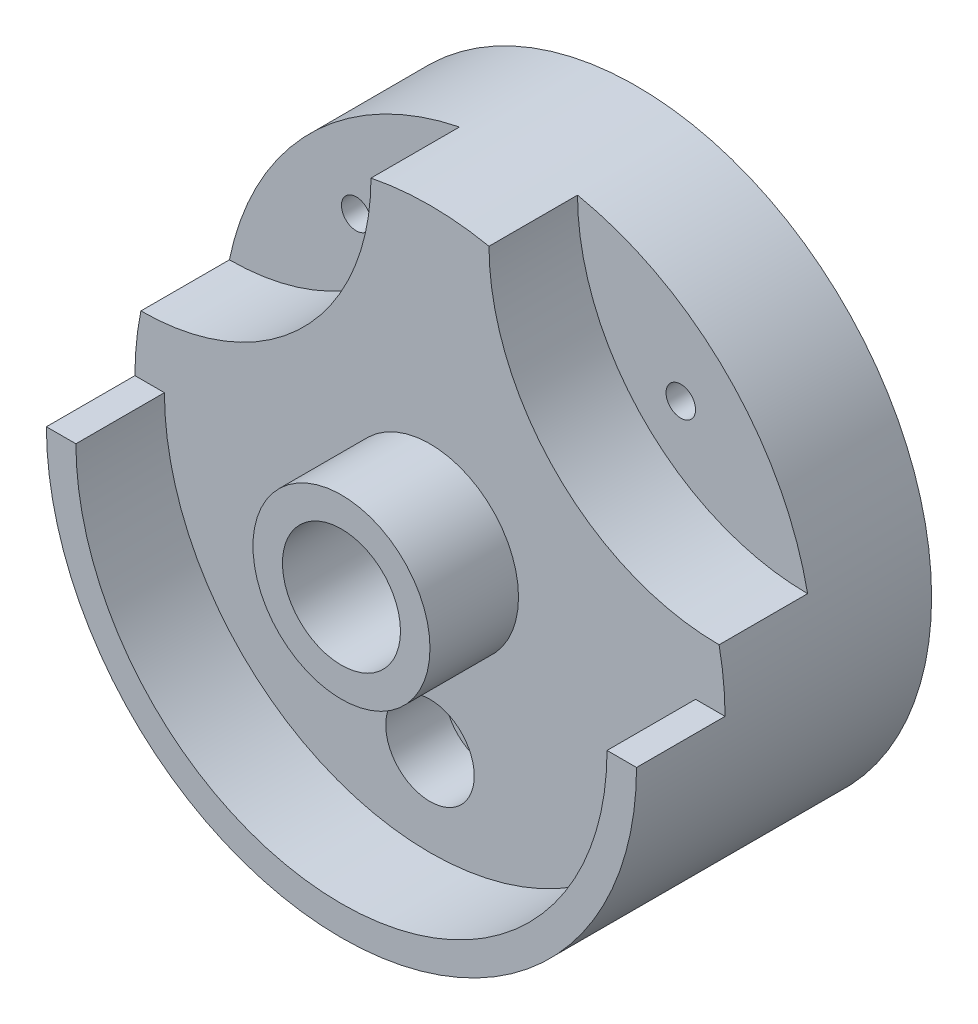
from build123d import *

# Parameters (mm, degrees)
SKETCH1_R           = 50
BOSS_EXTRUDE1_DEPTH = 20
BOSS_EXTRUDE3_DEPTH = 30
BOSS_EXTRUDE7_DEPTH = 15
SKETCH5_R           = 2.5
CUT_EXTRUDE1_DEPTH  = 43
SKETCH8_R           = 7.5
CUT_EXTRUDE4_DEPTH  = 10
SKETCH9_R           = 2.5
CUT_EXTRUDE5_DEPTH  = 90
SKETCH10_R          = 12.5
CUT_EXTRUDE6_DEPTH  = 10
SKETCH11_R          = 15
BOSS_EXTRUDE8_DEPTH = 15
SKETCH12_R          = 10
CUT_EXTRUDE7_DEPTH  = 105


with BuildPart() as part:
    # Sketch1 → Boss-Extrude1 (new body)
    with BuildSketch(Plane.XY):
        Circle(SKETCH1_R)
    extrude(amount=BOSS_EXTRUDE1_DEPTH)

    # Sketch2 → Boss-Extrude3 (add)
    with BuildSketch(Plane.XY.offset(20)):
        with BuildLine():
            Line((-50, 0), (-45, 0))
            ThreePointArc((-45, 0), (0, -45), (45, 0))
            Line((45, 0), (50, 0))
            ThreePointArc((50, 0), (0, -50), (-50, 0))
        make_face()
    extrude(amount=BOSS_EXTRUDE3_DEPTH)

    # Sketch4 → Boss-Extrude7 (add)
    with BuildSketch(Plane.XY.offset(20)):
        with BuildLine():
            ThreePointArc((-48.989794856, 10), (-49.74680765, 5.0254481), (-50, 0))
            Line((-50, 0), (-45, 0))
            ThreePointArc((-45, 0), (0, -45), (45, 0))
            Line((45, 0), (50, 0))
            ThreePointArc((50, 0), (49.74680765, 5.0254481), (48.989794856, 10))
            ThreePointArc((48.989794856, 10), (21.419846516, 21.419846516), (10, 48.989794856))
            ThreePointArc((10, 48.989794856), (0, 50), (-10, 48.989794856))
            ThreePointArc((-10, 48.989794856), (-21.419846516, 21.419846516), (-48.989794856, 10))
        make_face()
    extrude(amount=BOSS_EXTRUDE7_DEPTH)

    # Sketch5 → Cut-Extrude1 (cut)
    with BuildSketch(Plane.XY.offset(20)):
        with Locations((-27.5, 27.5)):
            Circle(SKETCH5_R)
        with Locations((27.5, 27.5)):
            Circle(SKETCH5_R)
    extrude(amount=-CUT_EXTRUDE1_DEPTH, mode=Mode.SUBTRACT)

    # Sketch8 → Cut-Extrude4 (cut)
    with BuildSketch(Plane.XY.offset(35)):
        with Locations((0, -30)):
            Circle(SKETCH8_R)
    extrude(amount=-CUT_EXTRUDE4_DEPTH, mode=Mode.SUBTRACT)

    # Sketch9 → Cut-Extrude5 (cut)
    with BuildSketch(Plane.XY.offset(25)):
        with Locations((0, -30)):
            Circle(SKETCH9_R)
    extrude(amount=-CUT_EXTRUDE5_DEPTH, mode=Mode.SUBTRACT)

    # Sketch10 → Cut-Extrude6 (cut)
    with BuildSketch(Plane(origin=(0, 0, 0), x_dir=(-1, 0, 0), z_dir=(0, 0, -1))):
        with Locations((0, -30)):
            Circle(SKETCH10_R)
    extrude(amount=-CUT_EXTRUDE6_DEPTH, mode=Mode.SUBTRACT)

    # Sketch11 → Boss-Extrude8 (add)
    with BuildSketch(Plane.XY.offset(35)):
        Circle(SKETCH11_R)
    extrude(amount=BOSS_EXTRUDE8_DEPTH)

    # Sketch12 → Cut-Extrude7 (cut)
    with BuildSketch(Plane.XY.offset(50)):
        Circle(SKETCH12_R)
    extrude(amount=-CUT_EXTRUDE7_DEPTH, mode=Mode.SUBTRACT)


solid = part.part
